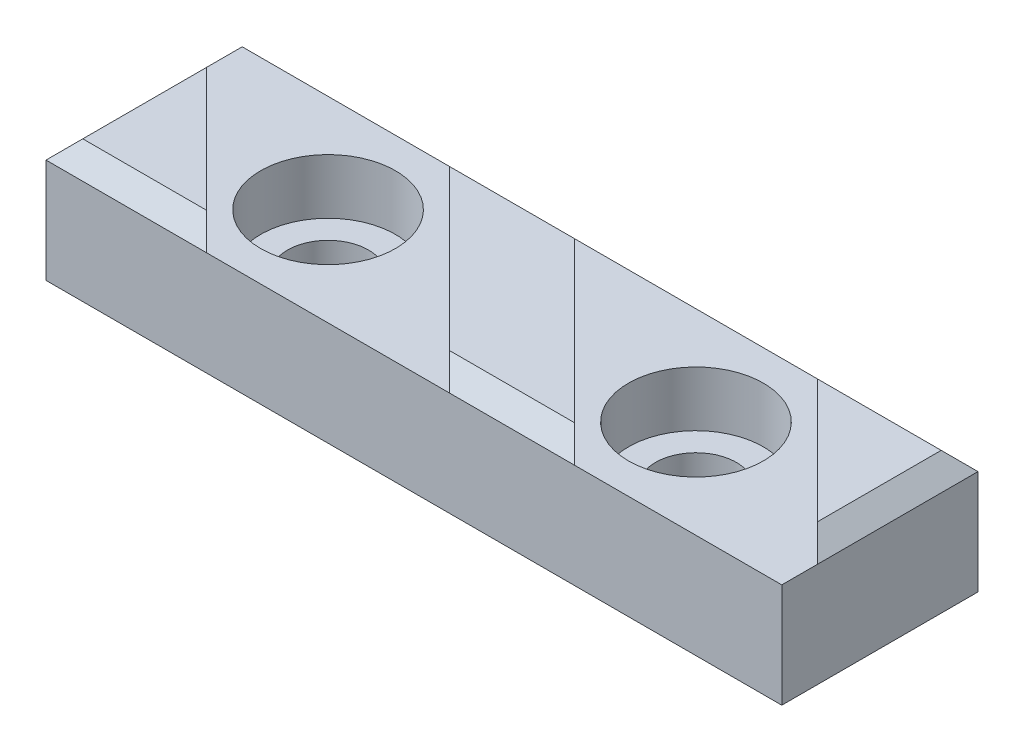
from build123d import *

# Parameters (mm, degrees)
SKETCH_1_W          = 60
SKETCH_1_H          = 16
EXTRUDE_1_DEPTH     = 8.5
SKETCH_2_R          = 5.5
CUT_EXTRUDE_1_DEPTH = 4.5
EXTRUDE_2_DEPTH     = 1.5
SKETCH_3_R          = 3.3
CUT_EXTRUDE_2_DEPTH = 63.385895842
CHAMFER_1_SIZE      = 1.5


with BuildPart() as part:
    # 草图1 → 凸台-拉伸1 (new body)
    with BuildSketch(Plane(origin=(0, 0, 0), x_dir=(1, 0, 0), z_dir=(0, 1, 0))):
        with Locations((30, 8)):
            Rectangle(SKETCH_1_W, SKETCH_1_H)
    extrude(amount=EXTRUDE_1_DEPTH)

    # 草图2 → 切除-拉伸1 (cut)
    with BuildSketch(Plane(origin=(0, 8.5, 0), x_dir=(1, 0, 0), z_dir=(0, 1, 0))):
        with Locations((15, 8)):
            Circle(SKETCH_2_R)
        with Locations((45, 8)):
            Circle(SKETCH_2_R)
    extrude(amount=-CUT_EXTRUDE_1_DEPTH, mode=Mode.SUBTRACT)

    # 草图2<3> → 凸台-拉伸2 (add)
    with BuildSketch(Plane(origin=(0, 8.5, 0), x_dir=(1, 0, 0), z_dir=(0, 1, 0))):
        Polygon((0, 13.100505063), (0, 0), (13.100505063, 0), align=None)
        Polygon((16.899494937, 16), (32.899494937, 0), (43.100505063, 0), (27.100505063, 16), align=None)
        Polygon((46.899494937, 16), (60, 2.899494937), (60, 16), align=None)
    extrude(amount=EXTRUDE_2_DEPTH)

    # 草图3 → 切除-拉伸2 (cut, through all)
    with BuildSketch(Plane(origin=(0, 4, 0), x_dir=(1, 0, 0), z_dir=(0, 1, 0))):
        with Locations((15, 8)):
            Circle(SKETCH_3_R)
        with Locations((45, 8)):
            Circle(SKETCH_3_R)
    extrude(amount=-CUT_EXTRUDE_2_DEPTH, mode=Mode.SUBTRACT)

    # 倒角1
    chamfer_1_edges = [part.edges().sort_by_distance(p)[0] for p in [
        (6.550252532, 10, 0),
        (0, 10, -6.550252532),
        (22, 10, -16),
        (38, 10, 0),
        (60, 10, -9.449747468),
        (53.449747468, 10, -16),
    ]]
    chamfer(chamfer_1_edges, length=CHAMFER_1_SIZE)


solid = part.part
